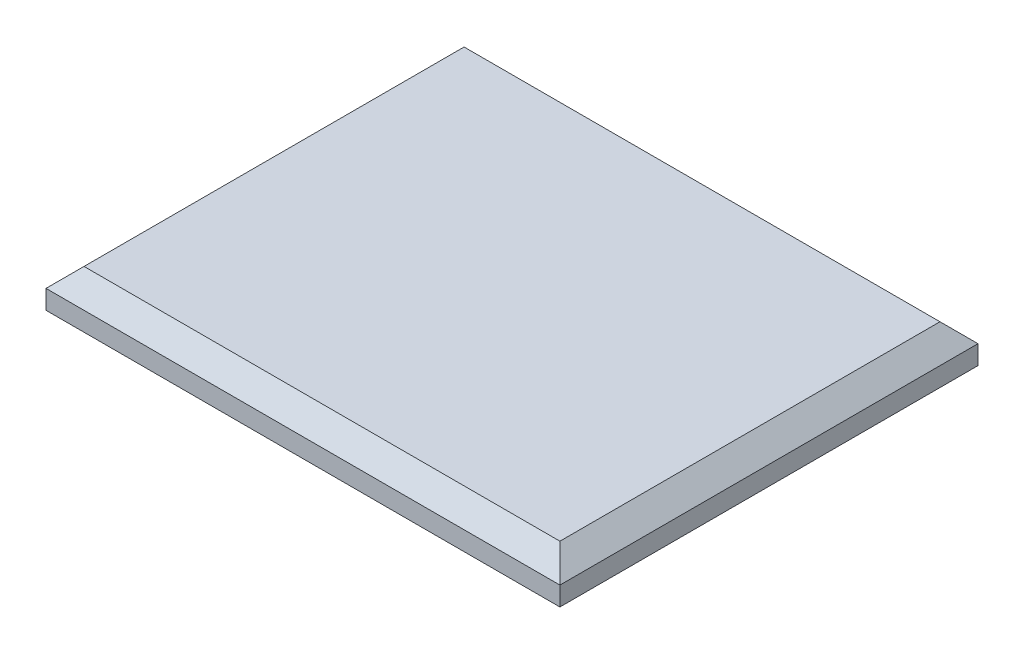
from build123d import *

# Parameters (mm, degrees)
SKETCH1_W           = 135.21
SKETCH1_H           = 110
BOSS_EXTRUDE1_DEPTH = 10
CHAMFER1_SIZE       = 5


with BuildPart() as part:
    # Sketch1 → Boss-Extrude1 (new body)
    with BuildSketch(Plane(origin=(0, 0, 0), x_dir=(1, 0, 0), z_dir=(0, 1, 0))):
        Rectangle(SKETCH1_W, SKETCH1_H)
    extrude(amount=BOSS_EXTRUDE1_DEPTH)

    # Chamfer1
    chamfer1_edges = [part.edges().sort_by_distance(p)[0] for p in [
        (-67.605, 10, 0),
        (0, 10, 55),
        (67.605, 10, 0),
        (0, 10, -55),
    ]]
    chamfer(chamfer1_edges, length=CHAMFER1_SIZE)


solid = part.part
